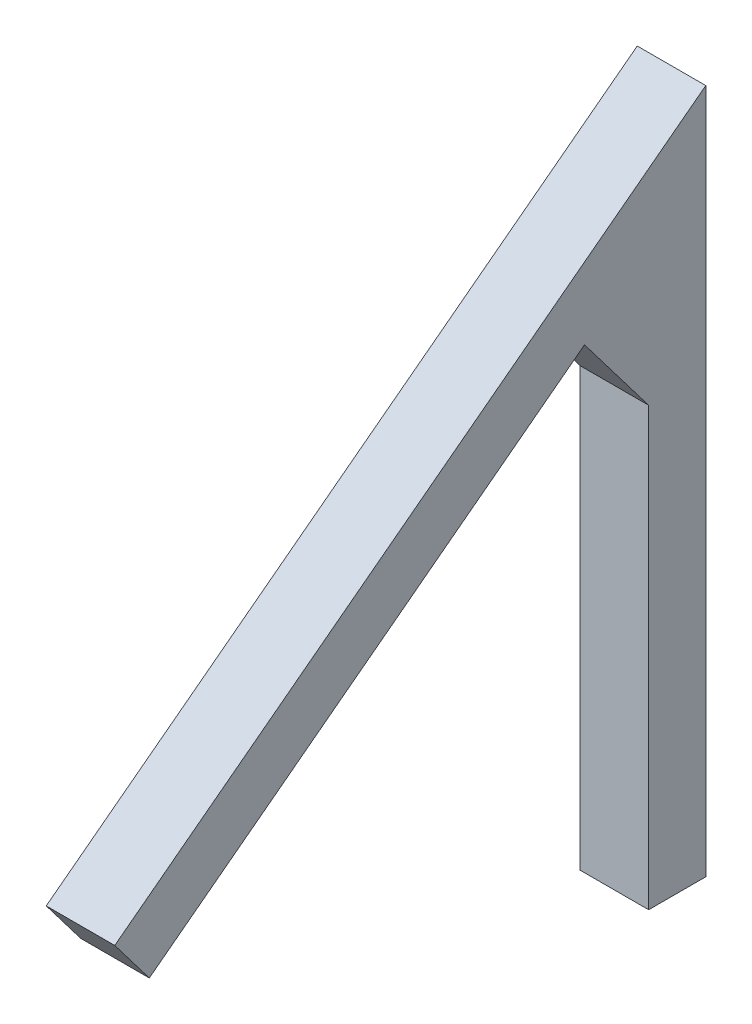
from build123d import *

# Parameters (mm, degrees)
BOSS_EXTRUDE1_DEPTH = 6


with BuildPart() as part:
    # Sketch1 → Boss-Extrude1 (new body)
    with BuildSketch(Plane(origin=(0, 0, 0), x_dir=(0, 0, -1), z_dir=(1, 0, 0))):
        Polygon((0, -14.968319992), (0, 45.031680008), (-51.750542618, 5.701267618), (-48.72512628, 1.720456648), (-10.618974655, 30.681131883), (-5, 23.287744178), (-5, -14.968319992), align=None)
    extrude(amount=BOSS_EXTRUDE1_DEPTH)


solid = part.part
